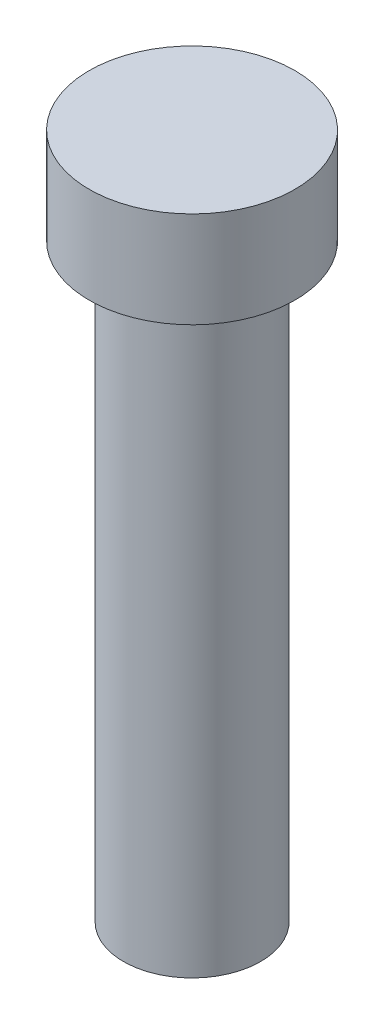
from build123d import *


with BuildPart() as part:
    # Sketch1 → Revolve1 (revolve)
    with BuildSketch(Plane.XY):
        Polygon((7.5, 50), (7.5, 43), (5, 43), (5, 0), (0, 0), (0, 50), align=None)
    revolve(axis=Axis((0, 0, 0), (0, 1, 0)))


solid = part.part
